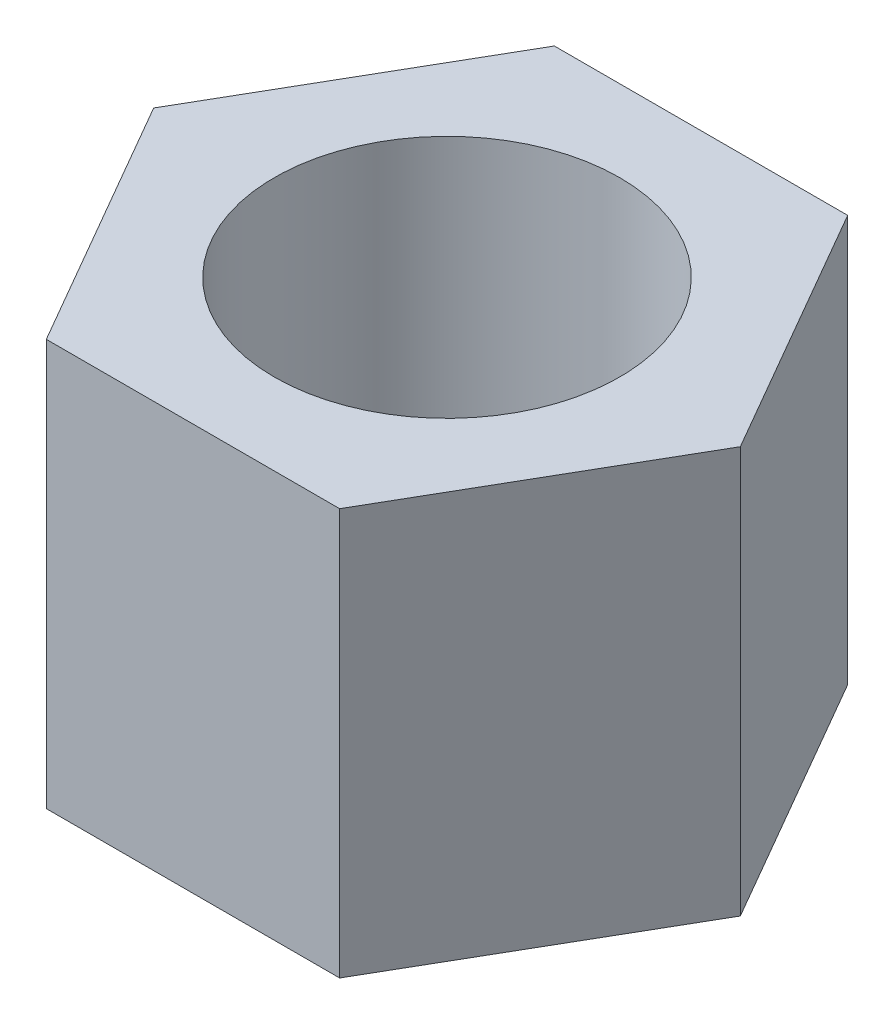
from build123d import *

# Parameters (mm, degrees)
SKETCH1_R           = 1.7
BOSS_EXTRUDE1_DEPTH = 2


with BuildPart() as part:
    # Sketch1 → Boss-Extrude1 (new body, symmetric)
    with BuildSketch(Plane(origin=(0, 0, 0), x_dir=(1, 0, 0), z_dir=(0, 1, 0))):
        Polygon((-2.886751346, 0), (-1.443375673, -2.5), (1.443375673, -2.5), (2.886751346, 0), (1.443375673, 2.5), (-1.443375673, 2.5), align=None)
        Circle(SKETCH1_R, mode=Mode.SUBTRACT)
    extrude(amount=BOSS_EXTRUDE1_DEPTH, both=True)


solid = part.part
